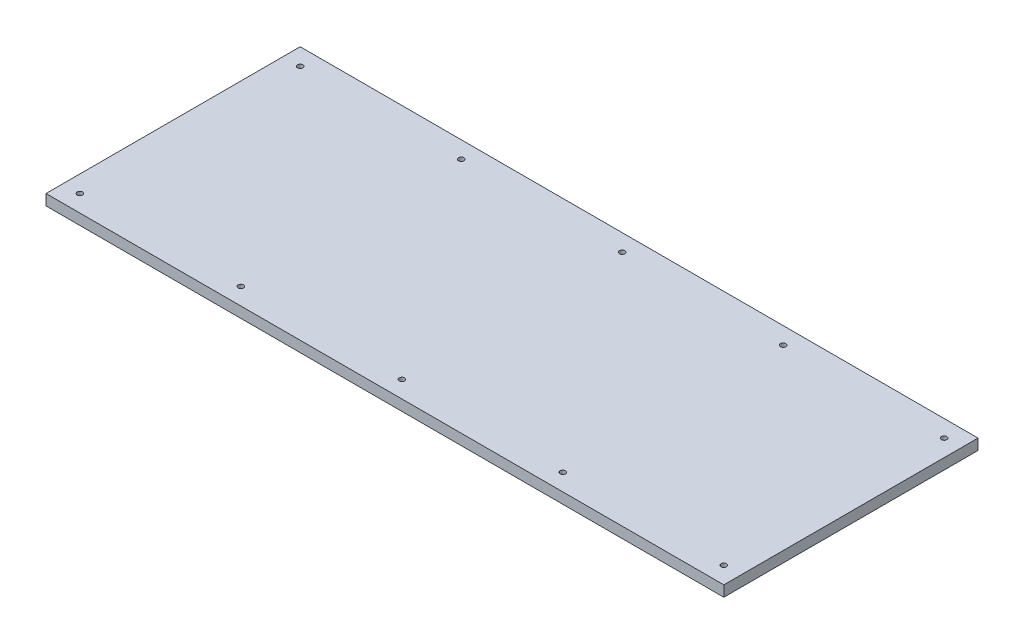
from build123d import *

# Parameters (mm, degrees)
PANEL_SKETCH_W           = 400
PANEL_SKETCH_H           = 150
PANEL_BOSS_EXTRUDE_DEPTH = 6.35
M3_CLEARANCE_HOLE1_D     = 3.2
LPATTERN1_COUNT          = 5
LPATTERN1_PITCH          = 95


with BuildPart() as part:
    # Panel Sketch → Panel Boss-Extrude (new body)
    with BuildSketch(Plane(origin=(0, 0, 0), x_dir=(1, 0, 0), z_dir=(0, 1, 0))):
        Rectangle(PANEL_SKETCH_W, PANEL_SKETCH_H)
    extrude(amount=-PANEL_BOSS_EXTRUDE_DEPTH)

    # M3 Clearance Hole1 (through all)
    with Locations(Plane(origin=(0, -6.35, 0), x_dir=(-1, 0, 0), z_dir=(0, -1, 0))):
        with Locations((190, 65), (190, -65)):
            m3_clearance_hole1 = Hole(M3_CLEARANCE_HOLE1_D / 2)

    # LPattern1: M3 Clearance Hole1 ×5
    with Locations(*[(i * LPATTERN1_PITCH, 0, 0) for i in range(1, LPATTERN1_COUNT)]):
        add(m3_clearance_hole1, mode=Mode.SUBTRACT)


solid = part.part
